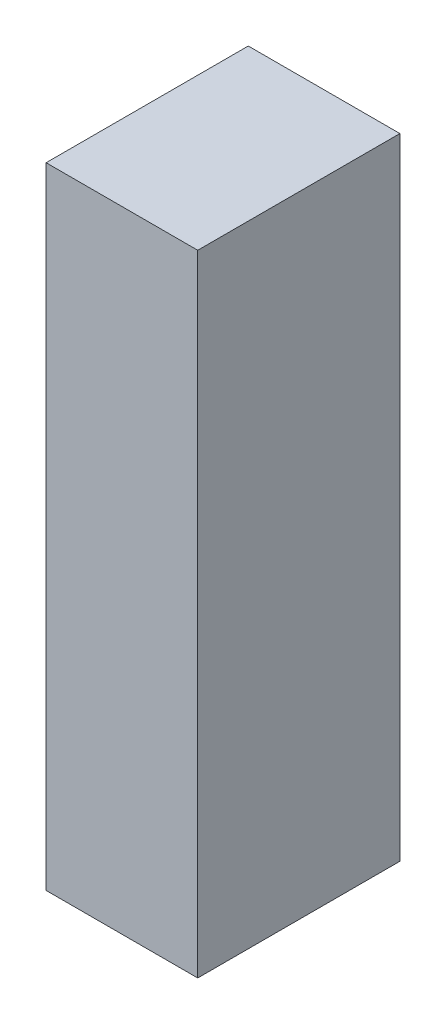
from build123d import *

# Parameters (mm, degrees)
SKETCH1_W           = 25.5
SKETCH1_H           = 106
BOSS_EXTRUDE1_DEPTH = 34


with BuildPart() as part:
    # Sketch1 → Boss-Extrude1 (new body)
    with BuildSketch(Plane.XY):
        with Locations((12.75, 53)):
            Rectangle(SKETCH1_W, SKETCH1_H)
    extrude(amount=BOSS_EXTRUDE1_DEPTH)


solid = part.part
